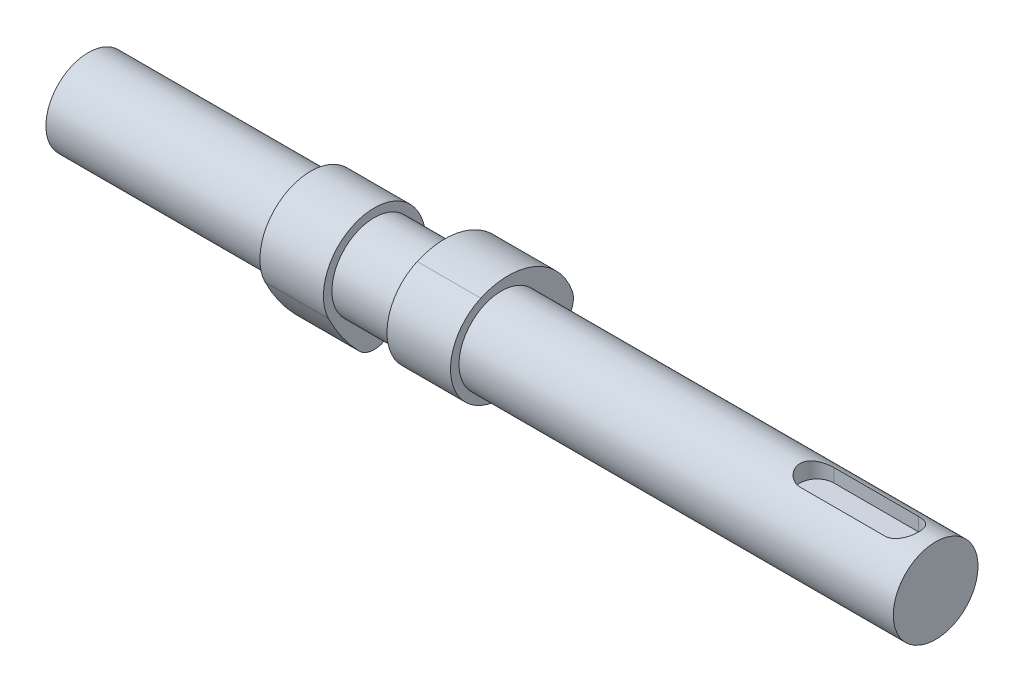
from build123d import *

# Parameters (mm, degrees)
SKETCH1_R                = 10
BOSS_EXTRUDE1_DEPTH      = 125
BOSS_EXTRUDE1_DEPTH_BACK = 75
BOSS_EXTRUDE2_START      = 15
BOSS_EXTRUDE2_DEPTH      = 7.5
BODY_MOVE_COPY1_ANGLE    = 90
CUT_EXTRUDE1_DEPTH       = 4


with BuildPart() as part:
    # Sketch1 → Boss-Extrude1 (new body, two sides)
    with BuildSketch(Plane(origin=(0, 0, 0), x_dir=(0, 0, -1), z_dir=(1, 0, 0))) as boss_extrude1_sk:
        Circle(SKETCH1_R)
    extrude(amount=BOSS_EXTRUDE1_DEPTH)
    extrude(boss_extrude1_sk.sketch, amount=-BOSS_EXTRUDE1_DEPTH_BACK)

    # Sketch4 → Cut-Extrude1 (cut)
    with BuildSketch(Plane(origin=(0, 10, 0), x_dir=(1, 0, 0), z_dir=(0, 1, 0))):
        with BuildLine():
            Line((117, -4), (97, -4))
            ThreePointArc((97, -4), (93, 0), (97, 4))
            Line((97, 4), (117, 4))
            ThreePointArc((117, 4), (121, 0), (117, -4))
        make_face()
    extrude(amount=-CUT_EXTRUDE1_DEPTH, mode=Mode.SUBTRACT)


with BuildPart() as body_2:
    # Sketch2 → Boss-Extrude2 (new body, symmetric)
    with BuildSketch(Plane(origin=(0, 0, 0), x_dir=(0, 0, -1), z_dir=(1, 0, 0)).offset(BOSS_EXTRUDE2_START)):
        with BuildLine():
            ThreePointArc((15.479542802, -3.587694386), (16.864464688, -1.143374761), (16.712672037, 1.661917746))
            ThreePointArc((16.712672037, 1.661917746), (7.958571112, 11.035699457), (-4.867089568, 10.968657125))
            ThreePointArc((-4.867089568, 10.968657125), (-10.868088345, -5.087696504), (5.306226617, -10.763083159))
            ThreePointArc((5.306226617, -10.763083159), (10.673744978, -7.573594418), (15.479542802, -3.587694386))
        make_face()
    extrude(amount=BOSS_EXTRUDE2_DEPTH, both=True)


with BuildPart() as body_3:
    # Mirror4: mirrored copy
    add(body_2.part.mirror(Plane(origin=(0, 0, 0), x_dir=(0, 0, 1), z_dir=(1, 0, 0))))


with BuildPart() as body_3_1:
    # Body-Move/Copy1: moved
    add(body_3.part.rotate(Axis((0, 0, 0), (-1, 0, 0)), BODY_MOVE_COPY1_ANGLE))


solid = Compound([part.part, body_2.part, body_3_1.part])
